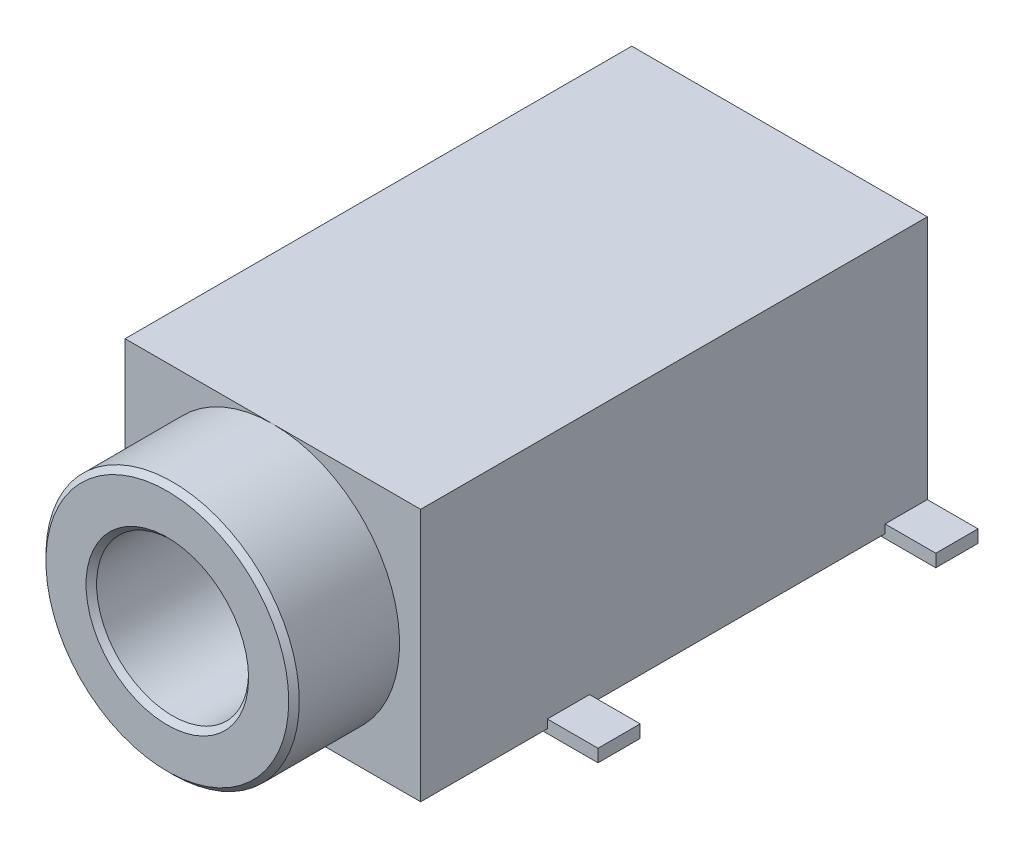
from build123d import *

# Parameters (mm, degrees)
ESQUISSE1_R             = 3
BOSS_EXTRU_1_DEPTH      = 2.5
ESQUISSE2_W             = 7
ESQUISSE2_H             = 6
BOSS_EXTRU_2_DEPTH      = 12
ESQUISSE4_R             = 1.8
ENL_V_MAT_EXTRU_2_DEPTH = 15.5
CHANFREIN2_SIZE         = 0.125
ESQUISSE5_R             = 0.55
BOSS_EXTRU_3_DEPTH      = 1
CONG_1_R                = 0.1
BOSS_EXTRU_4_START      = -0.2
ESQUISSE6_W             = 1.7
ESQUISSE6_H             = 1
BOSS_EXTRU_4_DEPTH      = 0.3
ESQUISSE7_W             = 1
ESQUISSE7_H             = 1.7
BOSS_EXTRU_5_DEPTH      = 0.1
BOSS_EXTRU_5_DEPTH_BACK = 0.2


with BuildPart() as part:
    # Esquisse1 → Boss.-Extru.1 (new body)
    with BuildSketch(Plane.XY):
        with Locations((0, 3)):
            Circle(ESQUISSE1_R)
    extrude(amount=BOSS_EXTRU_1_DEPTH)

    # Esquisse2 → Boss.-Extru.2 (add)
    with BuildSketch(Plane.XY):
        with Locations((0, 3)):
            Rectangle(ESQUISSE2_W, ESQUISSE2_H)
    extrude(amount=-BOSS_EXTRU_2_DEPTH)

    # Esquisse4 → Enlèv. mat.-Extru.2 (cut, through all)
    with BuildSketch(Plane.XY.offset(2.5)):
        with Locations((0, 3)):
            Circle(ESQUISSE4_R)
    extrude(amount=-ENL_V_MAT_EXTRU_2_DEPTH, mode=Mode.SUBTRACT)

    # Chanfrein2
    chanfrein2_edges = [part.edges().sort_by_distance(p)[0] for p in [
        (-1.8, 3, 2.5),
        (-3, 3, 2.5),
    ]]
    chamfer(chanfrein2_edges, length=CHANFREIN2_SIZE)

    # Esquisse5 → Boss.-Extru.3 (add)
    with BuildSketch(Plane.XZ):
        with Locations((0, -2)):
            Circle(ESQUISSE5_R)
        with Locations((0, -9)):
            Circle(ESQUISSE5_R)
    extrude(amount=BOSS_EXTRU_3_DEPTH)

    # Congé1
    cong_1_edges = [part.edges().sort_by_distance(p)[0] for p in [
        (-0.55, -1, -2),
        (-0.55, -1, -9),
    ]]
    fillet(cong_1_edges, radius=CONG_1_R)

    # Esquisse6 → Boss.-Extru.4 (add)
    with BuildSketch(Plane.XZ.offset(BOSS_EXTRU_4_START)):
        with Locations((-3.85, -3.5)):
            Rectangle(ESQUISSE6_W, ESQUISSE6_H)
        with Locations((-3.85, -11.5)):
            Rectangle(ESQUISSE6_W, ESQUISSE6_H)
    boss_extru_4 = extrude(amount=BOSS_EXTRU_4_DEPTH)

    # Symétrie1: Boss.-Extru.4 across plane
    add(boss_extru_4.mirror(Plane(origin=(0, 0, 0), x_dir=(0, 0, 1), z_dir=(1, 0, 0))))

    # Esquisse7 → Boss.-Extru.5 (add, two sides)
    with BuildSketch(Plane.XZ) as boss_extru_5_sk:
        with Locations((0, -12.35)):
            Rectangle(ESQUISSE7_W, ESQUISSE7_H)
    extrude(amount=BOSS_EXTRU_5_DEPTH)
    extrude(boss_extru_5_sk.sketch, amount=-BOSS_EXTRU_5_DEPTH_BACK)


solid = part.part
